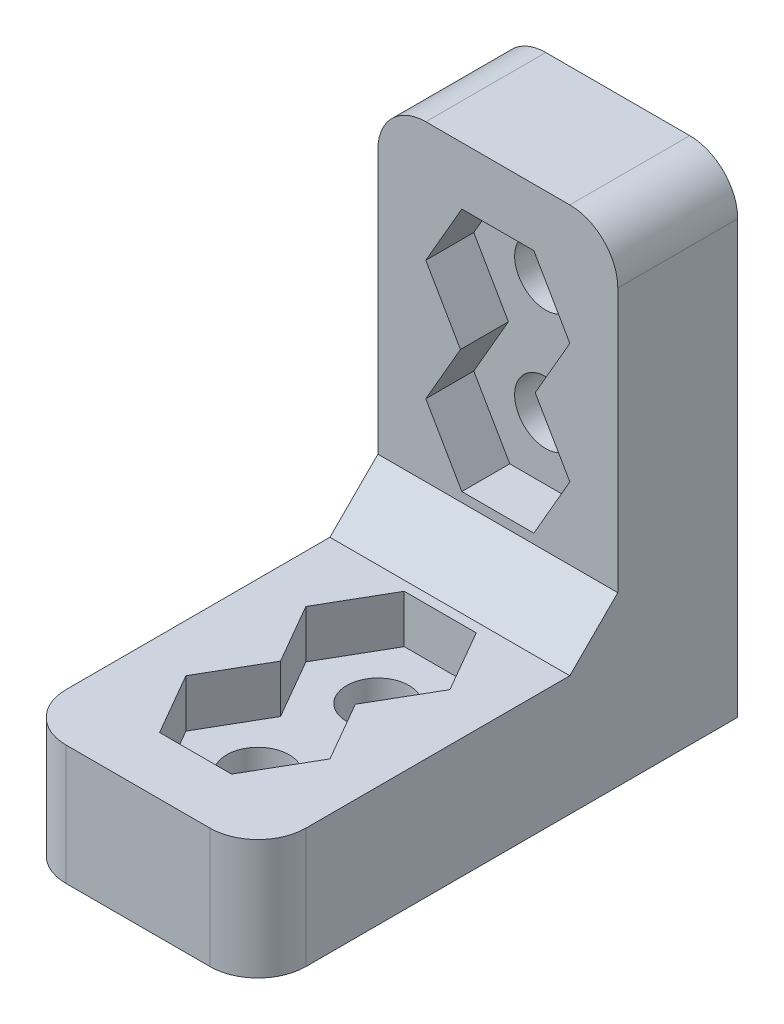
from build123d import *

# Parameters (mm, degrees)
BOSS_EXTRUDE1_DEPTH      = 6.35
BOSS_EXTRUDE1_DEPTH_BACK = 6.35
SKETCH2_R                = 1.651
CUT_EXTRUDE1_DEPTH       = 25.4
CUT_EXTRUDE2_DEPTH       = 2.54
SKETCH4_R                = 1.651
CUT_EXTRUDE3_DEPTH       = 6.35
CUT_EXTRUDE4_DEPTH       = 2.54
CHAMFER1_SIZE            = 2.54
FILLET1_R                = 2.54


with BuildPart() as part:
    # Sketch1 → Boss-Extrude1 (new, two sides: drawn at the far end of the back side and taken through both)
    with BuildSketch(Plane(origin=(0, 0, 0), x_dir=(0, 0, -1), z_dir=(1, 0, 0)).offset(-BOSS_EXTRUDE1_DEPTH_BACK)):
        Polygon((0, 0), (0, 19.05), (6.35, 19.05), (6.35, -6.35), (-19.05, -6.35), (-19.05, 0), align=None)
    extrude(amount=BOSS_EXTRUDE1_DEPTH + BOSS_EXTRUDE1_DEPTH_BACK)

    # Sketch2 → Cut-Extrude1 (cut)
    with BuildSketch(Plane(origin=(0, 0, 0), x_dir=(1, 0, 0), z_dir=(0, 1, 0))):
        with Locations((0, -6.35)):
            Circle(SKETCH2_R)
        with Locations((0, -12.7)):
            Circle(SKETCH2_R)
    extrude(amount=-CUT_EXTRUDE1_DEPTH, mode=Mode.SUBTRACT)

    # Sketch3 → Cut-Extrude2 (cut)
    with BuildSketch(Plane(origin=(0, 0, 0), x_dir=(1, 0, 0), z_dir=(0, 1, 0))):
        Polygon((1.906410589, -3.048), (-1.906410589, -3.048), (-3.812821178, -6.35), (-1.979734073, -9.525), (-3.812821178, -12.7), (-1.906410589, -16.002), (1.906410589, -16.002), (3.812821178, -12.7), (1.979734073, -9.525), (3.812821178, -6.35), align=None)
    extrude(amount=-CUT_EXTRUDE2_DEPTH, mode=Mode.SUBTRACT)

    # Sketch4 → Cut-Extrude3 (cut)
    with BuildSketch(Plane.XY):
        with Locations((0, 12.7)):
            Circle(SKETCH4_R)
        with Locations((0, 6.35)):
            Circle(SKETCH4_R)
    extrude(amount=-CUT_EXTRUDE3_DEPTH, mode=Mode.SUBTRACT)

    # Sketch5 → Cut-Extrude4 (cut)
    with BuildSketch(Plane.XY):
        Polygon((1.906410589, 16.002), (-1.906410589, 16.002), (-3.812821178, 12.7), (-1.979734073, 9.525), (-3.812821178, 6.35), (-1.906410589, 3.048), (1.906410589, 3.048), (3.812821178, 6.35), (1.979734073, 9.525), (3.812821178, 12.7), align=None)
    extrude(amount=-CUT_EXTRUDE4_DEPTH, mode=Mode.SUBTRACT)

    # Chamfer1
    chamfer1_edges = [part.edges().sort_by_distance(p)[0] for p in [
        (0, 0, 0),
    ]]
    chamfer(chamfer1_edges, length=CHAMFER1_SIZE)

    # Fillet1
    fillet1_edges = [part.edges().sort_by_distance(p)[0] for p in [
        (-6.35, -3.175, 19.05),
        (6.35, -3.175, 19.05),
        (6.35, 19.05, -3.175),
        (-6.35, 19.05, -3.175),
    ]]
    fillet(fillet1_edges, radius=FILLET1_R)


solid = part.part
